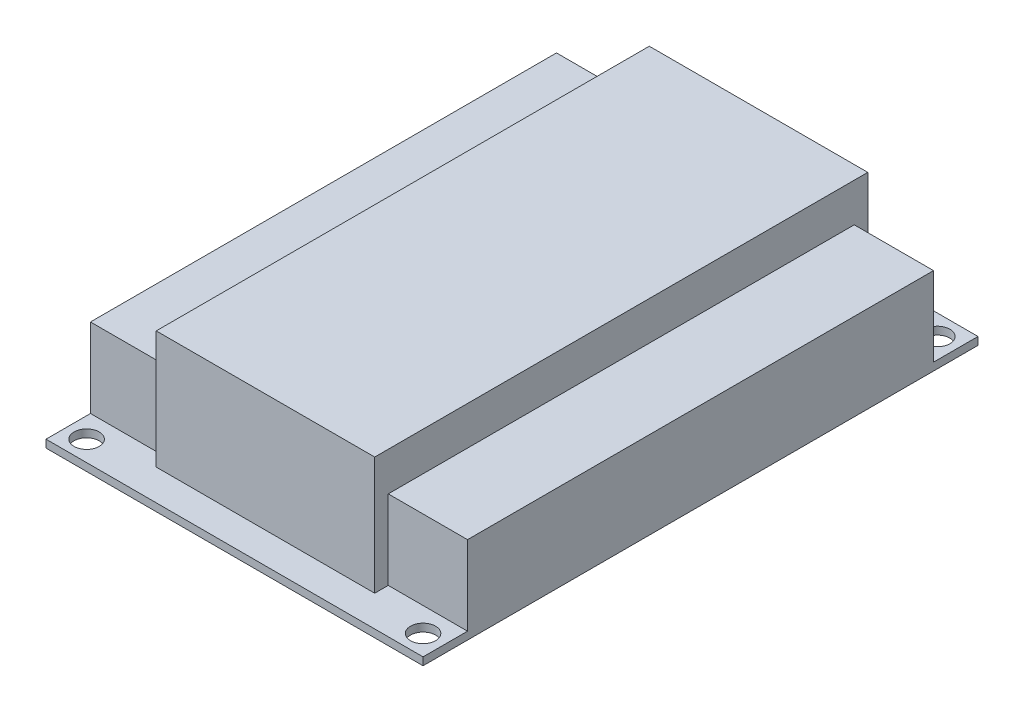
from build123d import *

# Parameters (mm, degrees)
BOSS_EXTRUDE1_DEPTH = 16.51
SKETCH1_6_W         = 10.414
SKETCH1_6_H         = 61.214
BOSS_EXTRUDE2_DEPTH = 11.43
SKETCH1_7_R         = 1.651
BOSS_EXTRUDE3_DEPTH = 1.016


with BuildPart() as part:
    # Sketch1 → Boss-Extrude1 (new body)
    with BuildSketch(Plane(origin=(0, 0, 0), x_dir=(1, 0, 0), z_dir=(0, 1, 0))):
        Polygon((-14.925727978, 32.087664761), (-14.925727978, 30.309664761), (-14.925727978, -30.904335239), (-14.925727978, -32.682335239), (13.776272022, -32.682335239), (13.776272022, -30.904335239), (13.776272022, 30.309664761), (13.776272022, 32.087664761), align=None)
    extrude(amount=BOSS_EXTRUDE1_DEPTH)

    # Sketch1_6 → Boss-Extrude2 (add)
    with BuildSketch(Plane(origin=(0, 0, 0), x_dir=(1, 0, 0), z_dir=(0, 1, 0))):
        with Locations((-20.132727978, -0.297335239)):
            Rectangle(SKETCH1_6_W, SKETCH1_6_H)
        with Locations((18.983272022, -0.297335239)):
            Rectangle(SKETCH1_6_W, SKETCH1_6_H)
    extrude(amount=BOSS_EXTRUDE2_DEPTH)

    # Sketch1_7 → Boss-Extrude3 (add)
    # profile 1 of 2: a face of its own
    with BuildSketch(Plane(origin=(0, 0, 0), x_dir=(1, 0, 0), z_dir=(0, 1, 0))):
        Polygon((-25.339727978, 36.151664761), (-25.339727978, 30.309664761), (-14.925727978, 30.309664761), (-14.925727978, 32.087664761), (13.776272022, 32.087664761), (13.776272022, 30.309664761), (24.190272022, 30.309664761), (24.190272022, 36.151664761), align=None)
        with Locations((-22.672727978, 33.484664761)):
            Circle(SKETCH1_7_R, mode=Mode.SUBTRACT)
        with Locations((21.523272022, 33.484664761)):
            Circle(SKETCH1_7_R, mode=Mode.SUBTRACT)
    # profile 2 of 2: a face of its own
    with BuildSketch(Plane(origin=(0, 0, 0), x_dir=(1, 0, 0), z_dir=(0, 1, 0))):
        Polygon((-14.925727978, -30.904335239), (-25.339727978, -30.904335239), (-25.339727978, -36.746335239), (24.190272022, -36.746335239), (24.190272022, -30.904335239), (13.776272022, -30.904335239), (13.776272022, -32.682335239), (-14.925727978, -32.682335239), align=None)
        with Locations((-22.672727978, -34.079335239)):
            Circle(SKETCH1_7_R, mode=Mode.SUBTRACT)
        with Locations((21.523272022, -34.079335239)):
            Circle(SKETCH1_7_R, mode=Mode.SUBTRACT)
    extrude(amount=BOSS_EXTRUDE3_DEPTH)


solid = part.part
